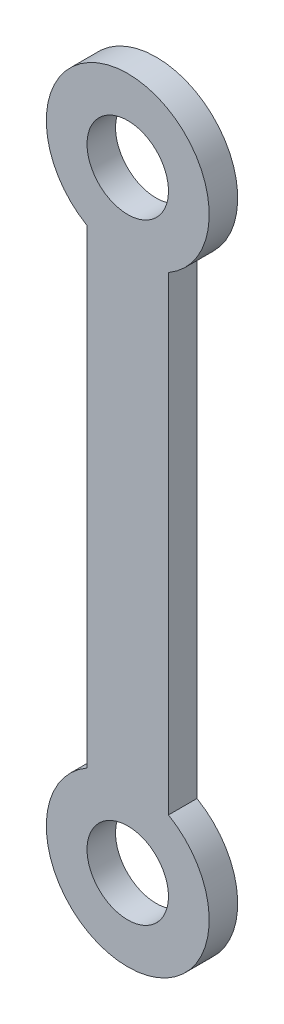
from build123d import *

# Parameters (mm, degrees)
SKETCH1_R           = 2
BOSS_EXTRUDE1_DEPTH = 1.4


with BuildPart() as part:
    # Sketch1 → Boss-Extrude1 (new body)
    with BuildSketch(Plane.XY):
        with BuildLine():
            Line((-2, 26.535898385), (-2, 3.464101615))
            ThreePointArc((-2, 3.464101615), (0, -4), (2, 3.464101615))
            Line((2, 3.464101615), (2, 26.535898385))
            ThreePointArc((2, 26.535898385), (0, 34), (-2, 26.535898385))
        make_face()
        Circle(SKETCH1_R, mode=Mode.SUBTRACT)
        with Locations((0, 30)):
            Circle(SKETCH1_R, mode=Mode.SUBTRACT)
    extrude(amount=BOSS_EXTRUDE1_DEPTH)


solid = part.part
